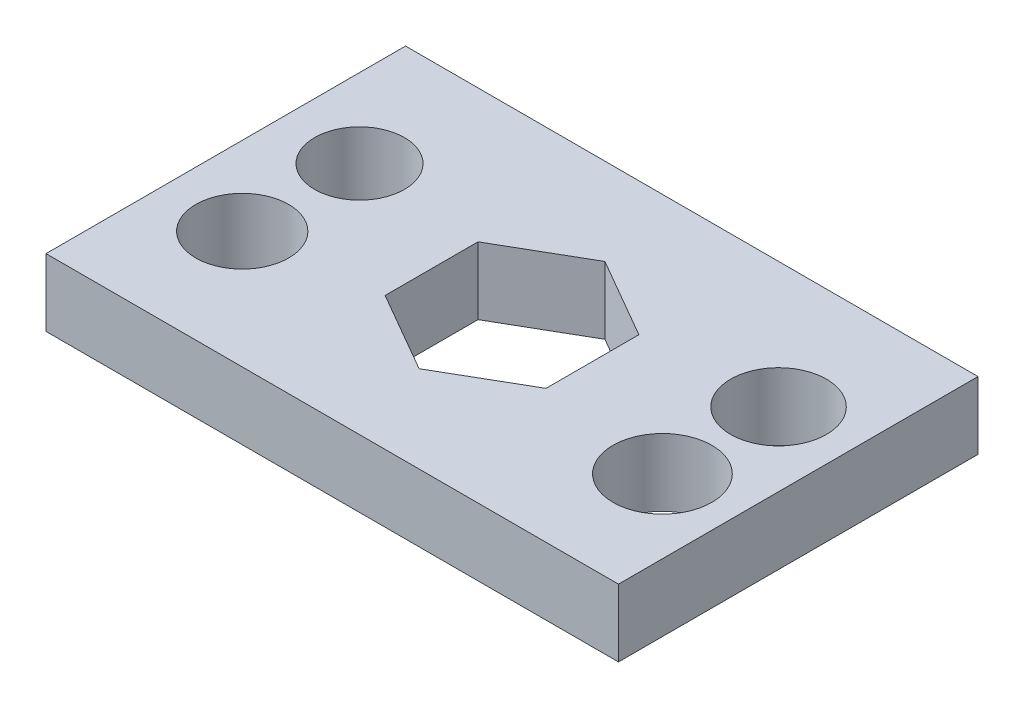
from build123d import *

# Parameters (mm, degrees)
SKETCH1_W           = 19.106827842
SKETCH1_H           = 12
SKETCH1_R           = 1.5
SKETCH1_R_2         = 1.6
SKETCH1_R_3         = 1.65
SKETCH1_R_4         = 1.55
BOSS_EXTRUDE1_DEPTH = 2.25


with BuildPart() as part:
    # Sketch1 → Boss-Extrude1 (new body)
    with BuildSketch(Plane(origin=(0, 0, 0), x_dir=(1, 0, 0), z_dir=(0, 1, 0))):
        Rectangle(SKETCH1_W, SKETCH1_H)
        with Locations((-6.925755231, 1.836983108)):
            Circle(SKETCH1_R, mode=Mode.SUBTRACT)
        with Locations((7.098878727, 1.797303867)):
            Circle(SKETCH1_R_2, mode=Mode.SUBTRACT)
        with Locations((7.098878727, -2.077930101)):
            Circle(SKETCH1_R_3, mode=Mode.SUBTRACT)
        with Locations((-6.925755231, -2.077930101)):
            Circle(SKETCH1_R_4, mode=Mode.SUBTRACT)
        Polygon((2.685, 1.550185473), (0, 3.100370946), (-2.685, 1.550185473), (-2.685, -1.550185473), (0, -3.100370946), (2.685, -1.550185473), align=None, mode=Mode.SUBTRACT)
    extrude(amount=BOSS_EXTRUDE1_DEPTH)


solid = part.part
